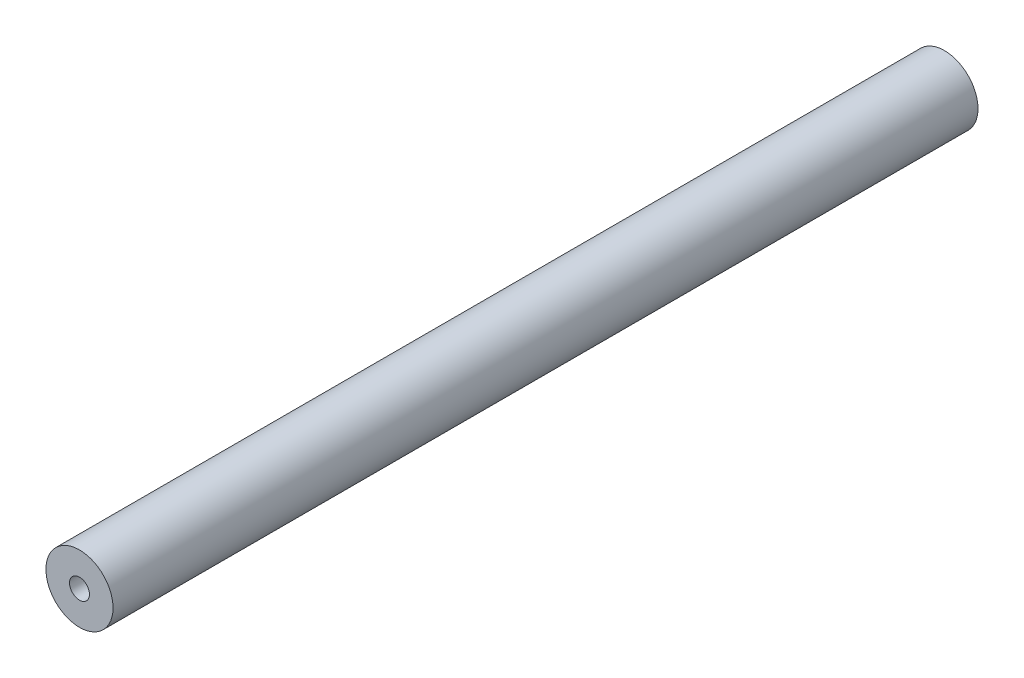
from build123d import *

# Parameters (mm, degrees)
SKETCH1_R                  = 6.4
BOSS_EXTRUDE1_DEPTH        = 165
F_10_24_TAPPED_HOLE1_D     = 3.7973
F_10_24_TAPPED_HOLE1_DEPTH = 12.83
F_10_24_TAPPED_HOLE1_TIP   = 1.140824014
F_10_24_TAPPED_HOLE2_D     = 3.7973
F_10_24_TAPPED_HOLE2_DEPTH = 12.83
F_10_24_TAPPED_HOLE2_TIP   = 1.140824014


with BuildPart() as part:
    # Sketch1 → Boss-Extrude1 (new body)
    with BuildSketch(Plane.XY):
        Circle(SKETCH1_R)
    extrude(amount=BOSS_EXTRUDE1_DEPTH)

    # #10-24 Tapped Hole1
    with Locations(Plane(origin=(0, 0, 0), x_dir=(-1, 0, 0), z_dir=(0, 0, -1))):
        with Locations((0, 0)):
            Hole(F_10_24_TAPPED_HOLE1_D / 2, depth=F_10_24_TAPPED_HOLE1_DEPTH)
            with Locations((0, 0, -(F_10_24_TAPPED_HOLE1_DEPTH + F_10_24_TAPPED_HOLE1_TIP / 2))):  # 118° drill point
                Cone(0, F_10_24_TAPPED_HOLE1_D / 2, F_10_24_TAPPED_HOLE1_TIP, mode=Mode.SUBTRACT)

    # #10-24 Tapped Hole2
    with Locations(Plane.XY.offset(165)):
        with Locations((0, 0)):
            Hole(F_10_24_TAPPED_HOLE2_D / 2, depth=F_10_24_TAPPED_HOLE2_DEPTH)
            with Locations((0, 0, -(F_10_24_TAPPED_HOLE2_DEPTH + F_10_24_TAPPED_HOLE2_TIP / 2))):  # 118° drill point
                Cone(0, F_10_24_TAPPED_HOLE2_D / 2, F_10_24_TAPPED_HOLE2_TIP, mode=Mode.SUBTRACT)


solid = part.part
